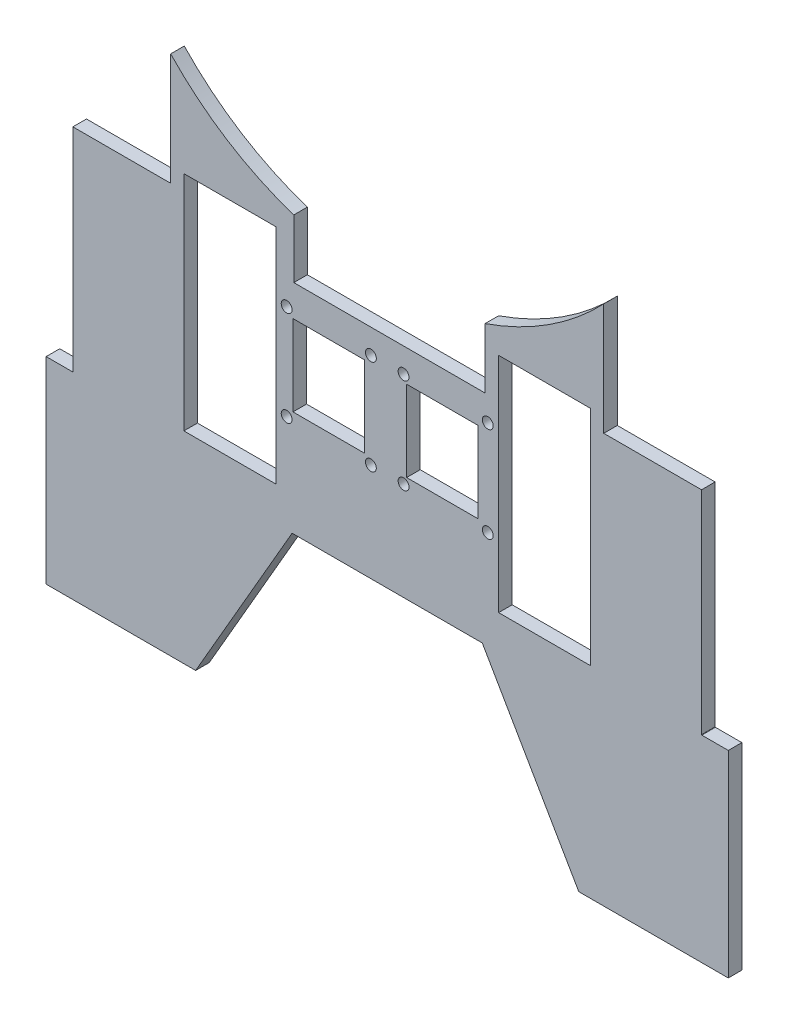
from build123d import *

# Parameters (mm, degrees)
SKETCH1_R           = 2
SKETCH1_W           = 33.838048367
SKETCH1_H           = 82.031632405
BOSS_EXTRUDE1_DEPTH = 5
SKETCH6_W           = 26.358753283
SKETCH6_H           = 29.759882739
CUT_EXTRUDE5_DEPTH  = 10
CUT_EXTRUDE7_DEPTH  = 10
SKETCH8_R           = 110
CUT_EXTRUDE8_DEPTH  = 10
SKETCH9_W           = 34.735720487
SKETCH9_H           = 8.029761027
BOSS_EXTRUDE2_DEPTH = 5
SKETCH10_W          = 47.255249557
SKETCH10_H          = 69.524861462
SKETCH10_W_2        = 47.255249556
CUT_EXTRUDE9_DEPTH  = 10


with BuildPart() as part:
    # Sketch1 → Boss-Extrude1 (new body)
    with BuildSketch(Plane.XY):
        with BuildLine():
            Line((-67.377293169, 102.297329585), (-124.936746461, 102.297329585))
            Line((-124.936746461, 102.297329585), (-124.953483971, 82.555494847))
            Line((-124.953483971, 82.555494847), (-124.958588565, 69.121872443))
            Line((-124.958588565, 69.121872443), (-124.95889847, 54.500614803))
            Line((-124.95889847, 54.500614803), (-115.116370276, 54.500614803))
            Line((-115.116370276, 54.500614803), (-115.116370276, -30.846433579))
            Line((-115.116370276, -30.846433579), (-124.960166164, -30.846433579))
            Line((-124.960166164, -30.846433579), (-124.960166164, -103.402915432))
            Line((-124.960166164, -103.402915432), (-69.927203874, -103.402915432))
            Line((-69.927203874, -103.402915432), (-34.406465086, -41.879191129))
            Line((-34.406465086, -41.879191129), (35.597608304, -41.879191129))
            Line((35.597608304, -41.879191129), (71.118347092, -103.402915432))
            Line((71.118347092, -103.402915432), (126.151309382, -103.402915432))
            Line((126.151309382, -103.402915432), (126.151309382, -30.846433579))
            Line((126.151309382, -30.846433579), (116.434490518, -30.846433579))
            ThreePointArc((116.434490518, -30.846433579), (116.344704203, -30.80924287), (116.307513493, -30.719456554))
            Line((116.307513493, -30.719456554), (116.307513493, 54.373637777))
            ThreePointArc((116.307513493, 54.373637777), (116.344704203, 54.463424093), (116.434490518, 54.500614803))
            Line((116.434490518, 54.500614803), (126.150041687, 54.500614803))
            Line((126.150041687, 54.500614803), (126.149731996, 69.11181019))
            Line((126.149731996, 69.11181019), (126.144618663, 82.565551548))
            Line((126.144618663, 82.565551548), (126.127889679, 102.297329585))
            Line((126.127889679, 102.297329585), (68.568436387, 102.297329585))
            ThreePointArc((68.568436387, 102.297329585), (0.595571609, 72.327090612), (-67.377293169, 102.297329585))
        make_face()
        with Locations((-5.420244594, -5.672909388)):
            Circle(SKETCH1_R, mode=Mode.SUBTRACT)
        with Locations((-36.420244594, -5.672909388)):
            Circle(SKETCH1_R, mode=Mode.SUBTRACT)
        with Locations((-36.420244594, 29.327090612)):
            Circle(SKETCH1_R, mode=Mode.SUBTRACT)
        with Locations((-5.420244594, 29.327090612)):
            Circle(SKETCH1_R, mode=Mode.SUBTRACT)
        with Locations((6.611387811, 29.327090612)):
            Circle(SKETCH1_R, mode=Mode.SUBTRACT)
        with Locations((6.611387811, -5.672909388)):
            Circle(SKETCH1_R, mode=Mode.SUBTRACT)
        with Locations((37.611387811, -5.672909388)):
            Circle(SKETCH1_R, mode=Mode.SUBTRACT)
        with Locations((37.611387811, 29.327090612)):
            Circle(SKETCH1_R, mode=Mode.SUBTRACT)
        with Locations((58.530411994, 11.827090612)):
            Rectangle(SKETCH1_W, SKETCH1_H, mode=Mode.SUBTRACT)
        with Locations((-57.339268778, 11.827090612)):
            Rectangle(SKETCH1_W, SKETCH1_H, mode=Mode.SUBTRACT)
    extrude(amount=BOSS_EXTRUDE1_DEPTH)

    # Sketch6 → Cut-Extrude5 (cut)
    with BuildSketch(Plane.XY.offset(5)):
        with Locations((-20.920244594, 11.827090611)):
            Rectangle(SKETCH6_W, SKETCH6_H)
        with Locations((20.920244594, 11.827090611)):
            Rectangle(SKETCH6_W, SKETCH6_H)
    extrude(amount=-CUT_EXTRUDE5_DEPTH, mode=Mode.SUBTRACT)

    # Sketch7 → Cut-Extrude7 (cut)
    with BuildSketch(Plane.XY.offset(5)):
        Polygon((36.611387811, 79.275951145), (36.611387811, 38.327090612), (-33.788939324, 38.327090612), (-33.788939324, 77.421207896), (-33.788939324, 95.121170758), (36.611387811, 95.121170758), align=None)
    extrude(amount=-CUT_EXTRUDE7_DEPTH, mode=Mode.SUBTRACT)

    # Sketch8 → Cut-Extrude8 (cut)
    with BuildSketch(Plane(origin=(0, 0, 0), x_dir=(-1, 0, 0), z_dir=(0, 0, -1))):
        with Locations((-0.595571609, 164.393850159)):
            Circle(SKETCH8_R)
    extrude(amount=-CUT_EXTRUDE8_DEPTH, mode=Mode.SUBTRACT)

    # Sketch9 → Boss-Extrude2 (add)
    with BuildSketch(Plane.XY.offset(5)):
        with Locations((-107.568886218, 106.312210099)):
            Rectangle(SKETCH9_W, SKETCH9_H)
        with Locations((108.760029436, 106.312210099)):
            Rectangle(SKETCH9_W, SKETCH9_H)
    extrude(amount=-BOSS_EXTRUDE2_DEPTH)

    # Sketch10 → Cut-Extrude9 (cut)
    with BuildSketch(Plane.XY.offset(5)):
        with Locations((103.935138271, 82.089521343)):
            Rectangle(SKETCH10_W, SKETCH10_H)
        with Locations((-102.743995054, 82.089521343)):
            Rectangle(SKETCH10_W_2, SKETCH10_H)
    extrude(amount=-CUT_EXTRUDE9_DEPTH, mode=Mode.SUBTRACT)


solid = part.part
